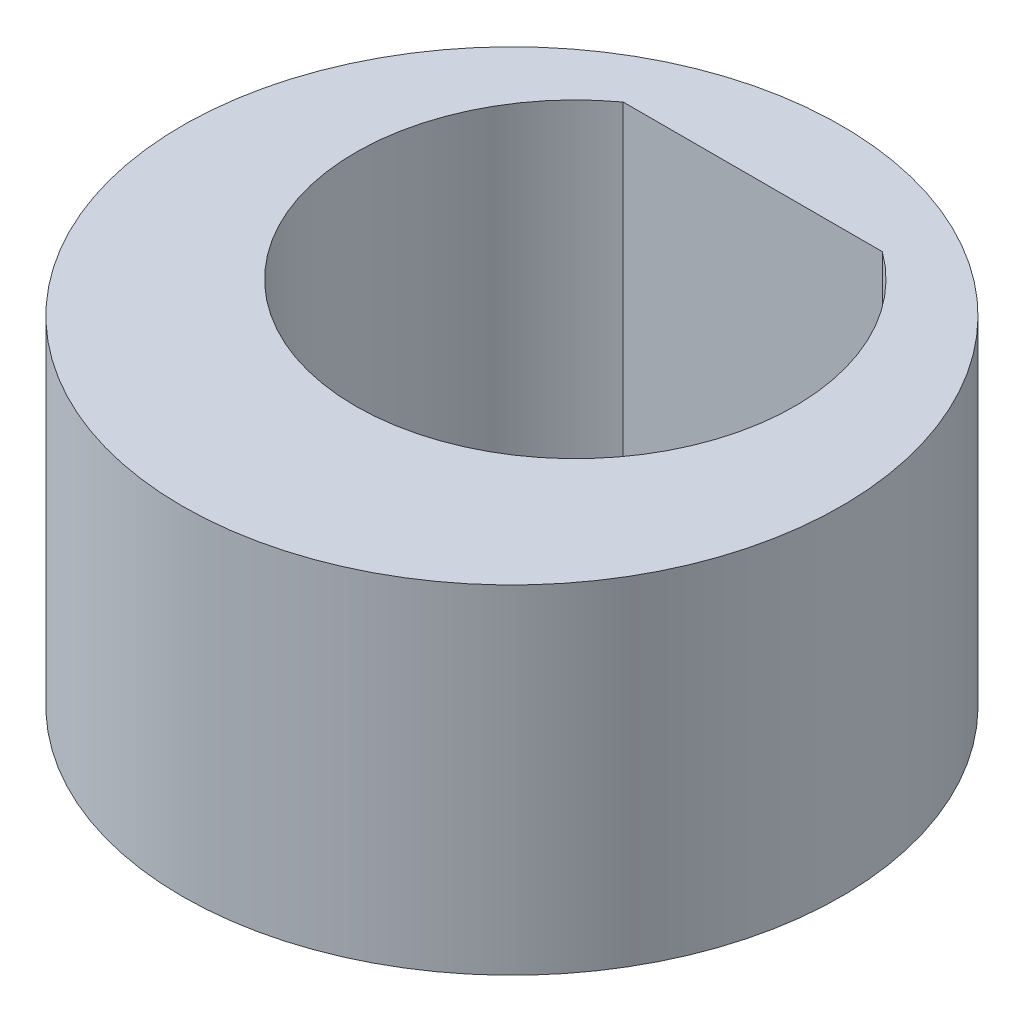
from build123d import *

# Parameters (mm, degrees)
SKETCH_1_R      = 3.9
EXTRUDE_1_DEPTH = 4


with BuildPart() as part:
    # 草图1 → 凸台-拉伸1 (new body)
    with BuildSketch(Plane(origin=(0, 0, 0), x_dir=(1, 0, 0), z_dir=(0, 1, 0))):
        with Locations((0, -0.75)):
            Circle(SKETCH_1_R)
        with BuildLine():
            Line((-1.532970972, 2.1), (1.532970972, 2.1))
            ThreePointArc((1.532970972, 2.1), (0, -2.6), (-1.532970972, 2.1))
        make_face(mode=Mode.SUBTRACT)
    extrude(amount=EXTRUDE_1_DEPTH)


solid = part.part
